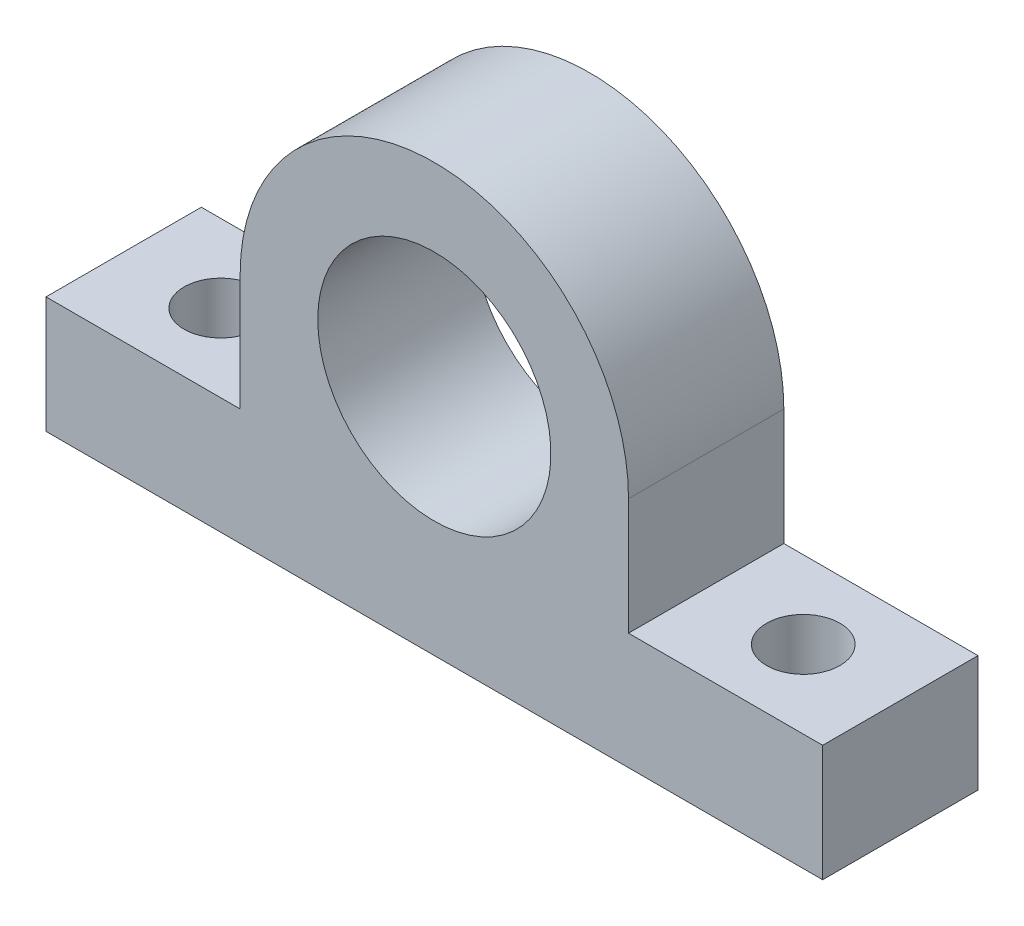
from build123d import *

# Parameters (mm, degrees)
SKETCH1_W                  = 63.5
SKETCH1_H                  = 19.05
SKETCH1_W_2                = 127
BOSS_EXTRUDE1_DEPTH        = 25.4
SKETCH5_R                  = 19.0627
CUT_EXTRUDE1_DEPTH         = 26.4
F_12_0_12_DIAMETER_HOLE1_D = 12


with BuildPart() as part:
    # Sketch1 → Boss-Extrude1 (new body)
    with BuildSketch(Plane.XY):
        with BuildLine():
            ThreePointArc((-31.75, 28.575), (0, 60.325), (31.75, 28.575))
            Line((31.75, 28.575), (-31.75, 28.575))
        make_face()
        with Locations((0, 19.05)):
            Rectangle(SKETCH1_W, SKETCH1_H)
        Rectangle(SKETCH1_W_2, SKETCH1_H)
    extrude(amount=BOSS_EXTRUDE1_DEPTH)

    # Sketch5 → Cut-Extrude1 (cut, through all)
    with BuildSketch(Plane(origin=(0, 0, 0), x_dir=(-1, 0, 0), z_dir=(0, 0, -1))):
        with Locations((0, 28.575)):
            Circle(SKETCH5_R)
    extrude(amount=-CUT_EXTRUDE1_DEPTH, mode=Mode.SUBTRACT)

    # Ø12.0 (12) Diameter Hole1 (through all)
    with Locations(Plane(origin=(0, 9.525, 0), x_dir=(1, 0, 0), z_dir=(0, 1, 0))):
        with Locations((-47.625, -12.7), (47.625, -12.7)):
            Hole(F_12_0_12_DIAMETER_HOLE1_D / 2)


solid = part.part
